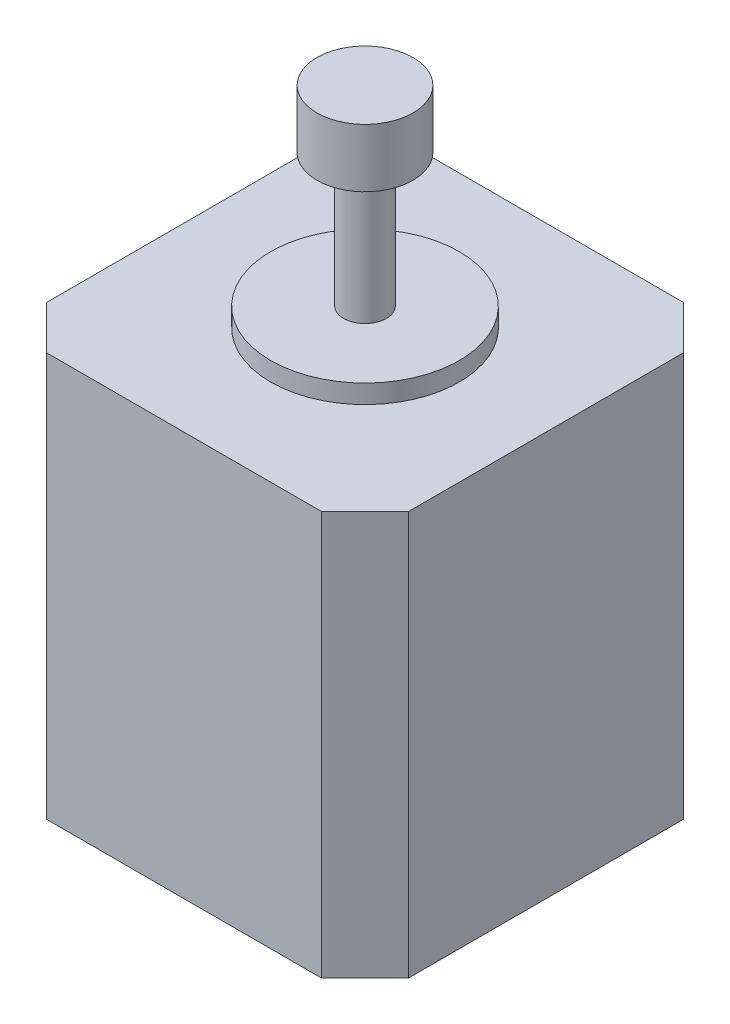
from build123d import *

# Parameters (mm, degrees)
SKETCH1_W           = 42.1386
SKETCH1_H           = 42.1386
BOSS_EXTRUDE1_DEPTH = 47.0281
SKETCH2_R           = 10.97915
BOSS_EXTRUDE2_DEPTH = 2.1717
SKETCH3_R           = 2.49555
BOSS_EXTRUDE3_DEPTH = 15.4686
CHAMFER1_SIZE       = 5.08
CHAMFER2_SIZE       = 5.08
CHAMFER3_SIZE       = 5.08
CHAMFER4_SIZE       = 5.08
SKETCH5_R           = 5.588
BOSS_EXTRUDE4_DEPTH = 6.7945


with BuildPart() as part:
    # Sketch1 → Boss-Extrude1 (new body)
    with BuildSketch(Plane(origin=(0, 0, 0), x_dir=(1, 0, 0), z_dir=(0, 1, 0))):
        with Locations((21.0693, 21.0693)):
            Rectangle(SKETCH1_W, SKETCH1_H)
    extrude(amount=BOSS_EXTRUDE1_DEPTH)

    # Sketch2 → Boss-Extrude2 (add)
    with BuildSketch(Plane(origin=(0, 47.0281, 0), x_dir=(1, 0, 0), z_dir=(0, 1, 0))):
        with Locations((21.0693, 21.0693)):
            Circle(SKETCH2_R)
    extrude(amount=BOSS_EXTRUDE2_DEPTH)

    # Sketch3 → Boss-Extrude3 (add)
    with BuildSketch(Plane(origin=(0, 49.1998, 0), x_dir=(1, 0, 0), z_dir=(0, 1, 0))):
        with Locations((21.0693, 21.0693)):
            Circle(SKETCH3_R)
    extrude(amount=BOSS_EXTRUDE3_DEPTH)

    # Chamfer1
    chamfer1_edges = [part.edges().sort_by_distance(p)[0] for p in [
        (42.1386, 23.51405, -42.1386),
    ]]
    chamfer(chamfer1_edges, length=CHAMFER1_SIZE)

    # Chamfer2
    chamfer2_edges = [part.edges().sort_by_distance(p)[0] for p in [
        (42.1386, 23.51405, 0),
    ]]
    chamfer(chamfer2_edges, length=CHAMFER2_SIZE)

    # Chamfer3
    chamfer3_edges = [part.edges().sort_by_distance(p)[0] for p in [
        (0, 23.51405, 0),
    ]]
    chamfer(chamfer3_edges, length=CHAMFER3_SIZE)

    # Chamfer4
    chamfer4_edges = [part.edges().sort_by_distance(p)[0] for p in [
        (0, 23.51405, -42.1386),
    ]]
    chamfer(chamfer4_edges, length=CHAMFER4_SIZE)

    # Sketch5 → Boss-Extrude4 (add)
    with BuildSketch(Plane(origin=(0, 64.6684, 0), x_dir=(1, 0, 0), z_dir=(0, 1, 0))):
        with Locations((21.0693, 21.0693)):
            Circle(SKETCH5_R)
    extrude(amount=BOSS_EXTRUDE4_DEPTH)


solid = part.part
